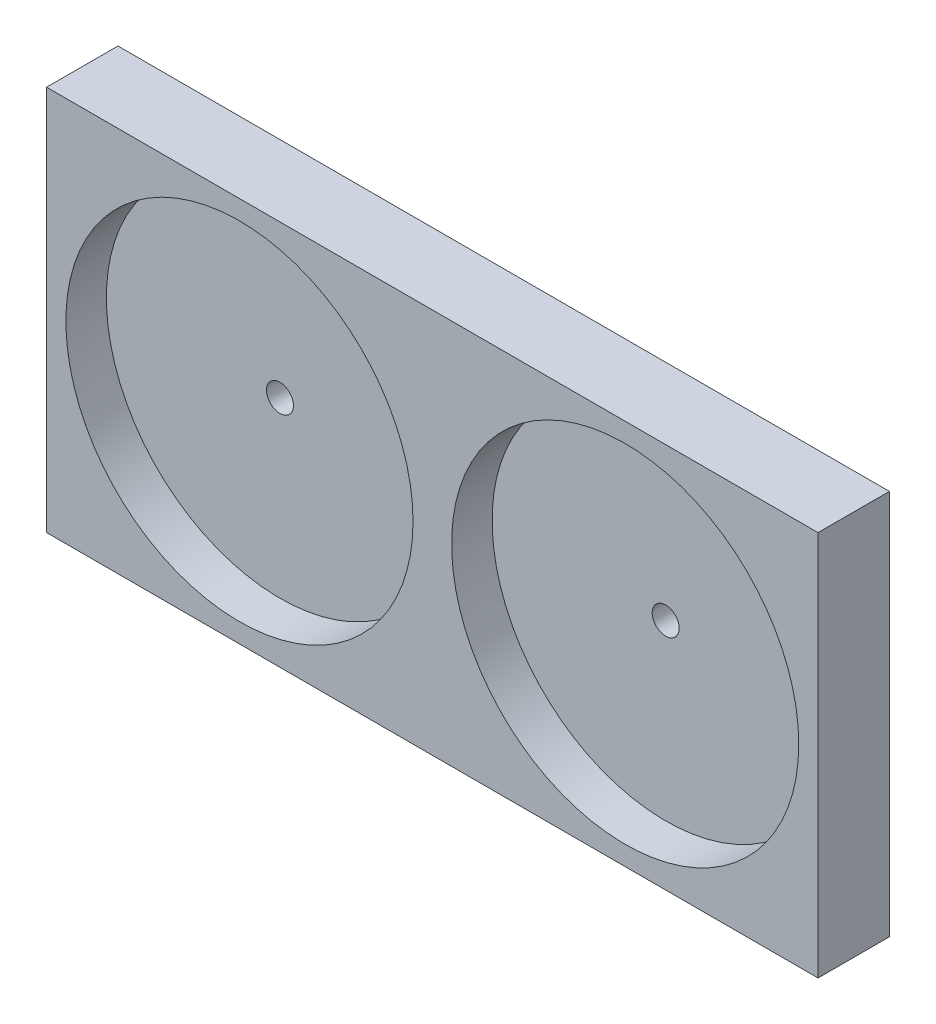
from build123d import *

# Parameters (mm, degrees)
SKETCH1_W           = 200
SKETCH1_H           = 100
BOSS_EXTRUDE1_DEPTH = 18.5
SKETCH2_R           = 45
CUT_EXTRUDE1_DEPTH  = 10.5
SKETCH3_R           = 3.5
CUT_EXTRUDE2_DEPTH  = 19.5
CUT_EXTRUDE4_DEPTH  = 3
CUT_EXTRUDE5_DEPTH  = 2


with BuildPart() as part:
    # Sketch1 → Boss-Extrude1 (new body)
    with BuildSketch(Plane.XY):
        with Locations((100, 50)):
            Rectangle(SKETCH1_W, SKETCH1_H)
    extrude(amount=BOSS_EXTRUDE1_DEPTH)

    # Sketch2 → Cut-Extrude1 (cut)
    with BuildSketch(Plane.XY.offset(18.5)):
        with Locations((50, 50)):
            Circle(SKETCH2_R)
        with Locations((150, 50)):
            Circle(SKETCH2_R)
    extrude(amount=-CUT_EXTRUDE1_DEPTH, mode=Mode.SUBTRACT)

    # Sketch3 → Cut-Extrude2 (cut, through all)
    with BuildSketch(Plane.XY.offset(18.5)):
        with Locations((50, 50)):
            Circle(SKETCH3_R)
        with Locations((150, 50)):
            Circle(SKETCH3_R)
    extrude(amount=-CUT_EXTRUDE2_DEPTH, mode=Mode.SUBTRACT)

    # Sketch4 → Cut-Extrude4 (cut)
    with BuildSketch(Plane(origin=(0, 0, 0), x_dir=(-1, 0, 0), z_dir=(0, 0, -1))):
        with BuildLine():
            Line((-133.600331897, 55.296115572), (-133.600331897, 25.39429873))
            ThreePointArc((-133.600331897, 25.39429873), (-150, 8.994630628), (-166.399668103, 25.39429873))
            Line((-166.399668103, 25.39429873), (-166.399668103, 55.296115572))
            ThreePointArc((-166.399668103, 55.296115572), (-150, 71.695783675), (-133.600331897, 55.296115572))
        make_face()
        with BuildLine():
            Line((-141.600331897, 55.296115572), (-141.600331897, 25.39429873))
            ThreePointArc((-141.600331897, 25.39429873), (-150, 16.994630628), (-158.399668103, 25.39429873))
            Line((-158.399668103, 25.39429873), (-158.399668103, 55.296115572))
            ThreePointArc((-158.399668103, 55.296115572), (-150, 63.695783675), (-141.600331897, 55.296115572))
        make_face(mode=Mode.SUBTRACT)
        with BuildLine():
            Line((-33.600331897, 55.296115572), (-33.600331897, 25.39429873))
            ThreePointArc((-33.600331897, 25.39429873), (-50, 8.994630628), (-66.399668103, 25.39429873))
            Line((-66.399668103, 25.39429873), (-66.399668103, 55.296115572))
            ThreePointArc((-66.399668103, 55.296115572), (-50, 71.695783675), (-33.600331897, 55.296115572))
        make_face()
        with BuildLine():
            Line((-41.600331897, 55.296115572), (-41.600331897, 25.39429873))
            ThreePointArc((-41.600331897, 25.39429873), (-50, 16.994630628), (-58.399668103, 25.39429873))
            Line((-58.399668103, 25.39429873), (-58.399668103, 55.296115572))
            ThreePointArc((-58.399668103, 55.296115572), (-50, 63.695783675), (-41.600331897, 55.296115572))
        make_face(mode=Mode.SUBTRACT)
    extrude(amount=-CUT_EXTRUDE4_DEPTH, mode=Mode.SUBTRACT)

    # Sketch5 → Cut-Extrude5 (cut)
    with BuildSketch(Plane(origin=(0, 0, 0), x_dir=(-1, 0, 0), z_dir=(0, 0, -1))):
        with BuildLine():
            Line((-110.1200005, 32.2499995), (-89.8000005, 32.2499995))
            ThreePointArc((-89.8000005, 32.2499995), (-87.8000005, 30.2499995), (-89.8000005, 28.2499995))
            Line((-89.8000005, 28.2499995), (-110.1200005, 28.2499995))
            ThreePointArc((-110.1200005, 28.2499995), (-112.1200005, 30.2499995), (-110.1200005, 32.2499995))
        make_face()
        with BuildLine():
            Line((-110.1200005, 16.9999995), (-89.8000005, 16.9999995))
            ThreePointArc((-89.8000005, 16.9999995), (-87.8000005, 14.9999995), (-89.8000005, 12.9999995))
            Line((-89.8000005, 12.9999995), (-110.1200005, 12.9999995))
            ThreePointArc((-110.1200005, 12.9999995), (-112.1200005, 14.9999995), (-110.1200005, 16.9999995))
        make_face()
    extrude(amount=-CUT_EXTRUDE5_DEPTH, mode=Mode.SUBTRACT)


solid = part.part
